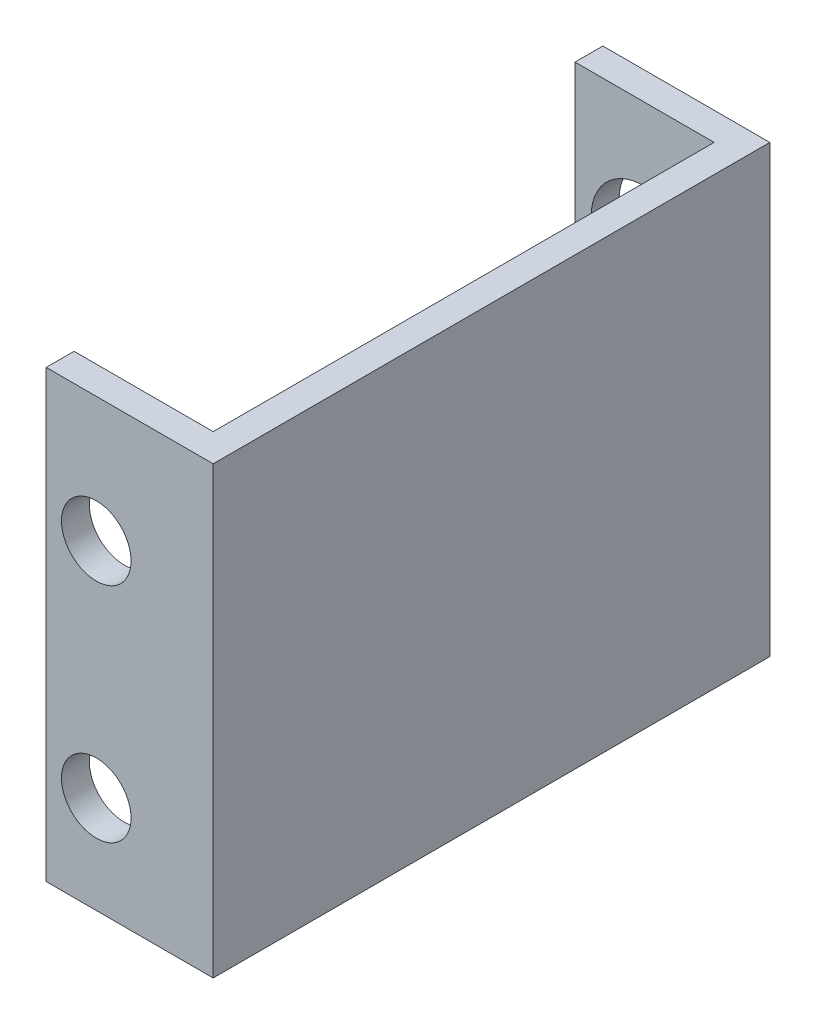
from build123d import *

# Parameters (mm, degrees)
BOSS_EXTRUDE3_DEPTH    = 50.8
SKETCH8_R              = 6
PANEL_MOUNT_HOLE_DEPTH = 4
CUT_EXTRUDE1_REACH     = 5.18
SKETCH9_R              = 3.96875


with BuildPart() as part:
    # Sketch1 → Boss-Extrude3 (new body)
    with BuildSketch(Plane(origin=(0, 0, 0), x_dir=(1, 0, 0), z_dir=(0, 1, 0))):
        Polygon((-19.05, 63.5), (-19.05, 60.325), (-3.175, 60.325), (-3.175, 3.18), (-19.05, 3.18), (-19.05, 0), (0, 0), (0, 63.5), align=None)
    extrude(amount=BOSS_EXTRUDE3_DEPTH)

    # Sketch8 → Panel Mount Hole (cut)
    with BuildSketch(Plane(origin=(0, 0, -63.5), x_dir=(-1, 0, 0), z_dir=(0, 0, -1))):
        with Locations((11.2, 36.5125)):
            Circle(SKETCH8_R)
    extrude(amount=-PANEL_MOUNT_HOLE_DEPTH, mode=Mode.SUBTRACT)

    # Sketch9 → Cut-Extrude1 (cut, up to next)
    with BuildSketch(Plane(origin=(0, 0, -3.18), x_dir=(-1, 0, 0), z_dir=(0, 0, -1)), mode=Mode.PRIVATE) as cut_extrude1_sk1:
        with Locations((13.335, 36.5125)):
            Circle(SKETCH9_R)
    cut_extrude1_tool1 = extrude(cut_extrude1_sk1.sketch, amount=-CUT_EXTRUDE1_REACH, mode=Mode.PRIVATE) & part.part
    add(cut_extrude1_tool1.solids().sort_by_distance((-13.335, 36.5125, -3.18))[0], mode=Mode.SUBTRACT)
    # Sketch9 → Cut-Extrude1 (cut, up to next)
    with BuildSketch(Plane(origin=(0, 0, -3.18), x_dir=(-1, 0, 0), z_dir=(0, 0, -1)), mode=Mode.PRIVATE) as cut_extrude1_sk2:
        with Locations((13.335, 11.1125)):
            Circle(SKETCH9_R)
    cut_extrude1_tool2 = extrude(cut_extrude1_sk2.sketch, amount=-CUT_EXTRUDE1_REACH, mode=Mode.PRIVATE) & part.part
    add(cut_extrude1_tool2.solids().sort_by_distance((-13.335, 11.1125, -3.18))[0], mode=Mode.SUBTRACT)


solid = part.part
